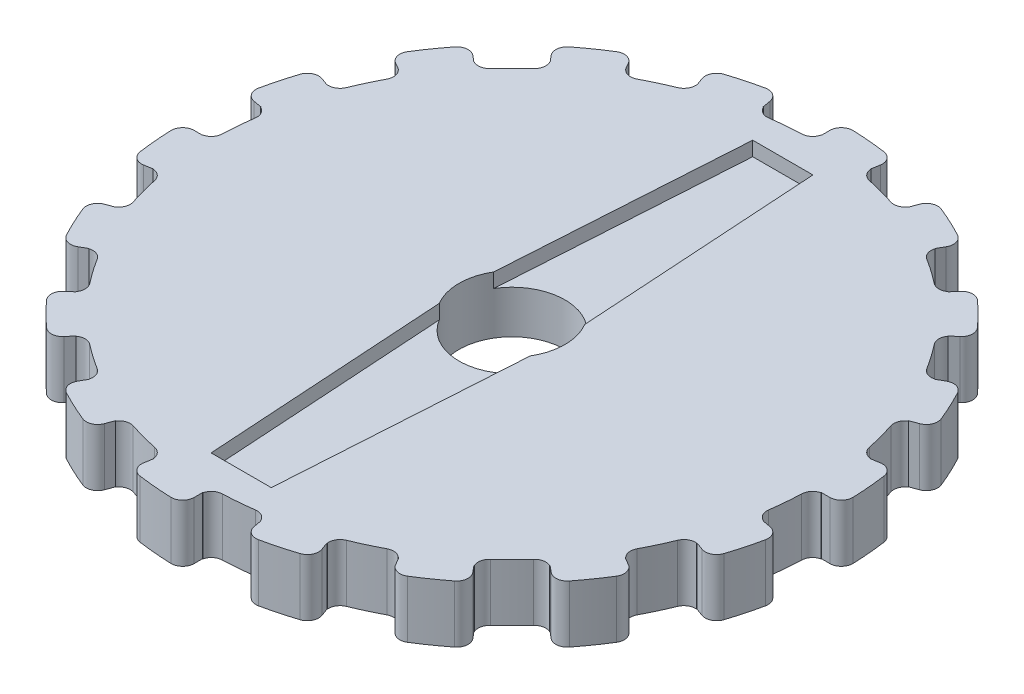
from build123d import *

# Parameters (mm, degrees)
CROQUIS1_R              = 3.7
SALIENTE_EXTRUIR1_DEPTH = 4
CORTAR_EXTRUIR1_START   = -1
CORTAR_EXTRUIR1_DEPTH   = 1
CORTAR_EXTRUIR2_START   = -4
CORTAR_EXTRUIR2_DEPTH   = 4
MATRIZC1_COUNT          = 18
ESCALA1_SCALE           = 0.99


with BuildPart() as part:
    # Croquis1 → Saliente-Extruir1 (new body)
    with BuildSketch(Plane(origin=(0, 0, 0), x_dir=(1, 0, 0), z_dir=(0, 1, 0))):
        with BuildLine():
            Line((3.750800638, 21.271847465), (4.167556264, 23.635386072))
            ThreePointArc((4.167556264, 23.635386072), (2.091737826, 23.908672754), (0, 24))
            Line((0, 24), (0, 21.6))
            ThreePointArc((0, 21.6), (-1.882564043, 21.517805479), (-3.750800638, 21.271847465))
            Line((-3.750800638, 21.271847465), (-4.167556264, 23.635386072))
            ThreePointArc((-4.167556264, 23.635386072), (-6.211657082, 23.182219831), (-8.20848344, 22.552622899))
            Line((-8.20848344, 22.552622899), (-7.387635096, 20.297360609))
            ThreePointArc((-7.387635096, 20.297360609), (-9.128554454, 19.5762482), (-10.8, 18.706148722))
            Line((-10.8, 18.706148722), (-12, 20.784609691))
            ThreePointArc((-12, 20.784609691), (-13.765834472, 19.659649063), (-15.426902632, 18.385066635))
            Line((-15.426902632, 18.385066635), (-13.884212369, 16.546559971))
            ThreePointArc((-13.884212369, 16.546559971), (-15.273506474, 15.273506474), (-16.546559971, 13.884212369))
            Line((-16.546559971, 13.884212369), (-18.385066635, 15.426902632))
            ThreePointArc((-18.385066635, 15.426902632), (-19.659649063, 13.765834472), (-20.784609691, 12))
            Line((-20.784609691, 12), (-18.706148722, 10.8))
            ThreePointArc((-18.706148722, 10.8), (-19.5762482, 9.128554454), (-20.297360609, 7.387635096))
            Line((-20.297360609, 7.387635096), (-22.552622899, 8.20848344))
            ThreePointArc((-22.552622899, 8.20848344), (-23.182219831, 6.211657082), (-23.635386072, 4.167556264))
            Line((-23.635386072, 4.167556264), (-21.271847465, 3.750800638))
            ThreePointArc((-21.271847465, 3.750800638), (-21.517805479, 1.882564043), (-21.6, 0))
            Line((-21.6, 0), (-24, 0))
            ThreePointArc((-24, 0), (-23.908672754, -2.091737826), (-23.635386072, -4.167556264))
            Line((-23.635386072, -4.167556264), (-21.271847465, -3.750800638))
            ThreePointArc((-21.271847465, -3.750800638), (-20.863997848, -5.590491374), (-20.297360609, -7.387635096))
            Line((-20.297360609, -7.387635096), (-22.552622899, -8.20848344))
            ThreePointArc((-22.552622899, -8.20848344), (-21.751386889, -10.142838282), (-20.784609691, -12))
            Line((-20.784609691, -12), (-18.706148722, -10.8))
            ThreePointArc((-18.706148722, -10.8), (-17.693684157, -12.389251025), (-16.546559971, -13.884212369))
            Line((-16.546559971, -13.884212369), (-18.385066635, -15.426902632))
            ThreePointArc((-18.385066635, -15.426902632), (-16.970562748, -16.970562748), (-15.426902632, -18.385066635))
            Line((-15.426902632, -18.385066635), (-13.884212369, -16.546559971))
            ThreePointArc((-13.884212369, -16.546559971), (-12.389251025, -17.693684157), (-10.8, -18.706148722))
            Line((-10.8, -18.706148722), (-12, -20.784609691))
            ThreePointArc((-12, -20.784609691), (-10.142838282, -21.751386889), (-8.20848344, -22.552622899))
            Line((-8.20848344, -22.552622899), (-7.387635096, -20.297360609))
            ThreePointArc((-7.387635096, -20.297360609), (-5.590491374, -20.863997848), (-3.750800638, -21.271847465))
            Line((-3.750800638, -21.271847465), (-4.167556264, -23.635386072))
            ThreePointArc((-4.167556264, -23.635386072), (-2.091737826, -23.908672754), (0, -24))
            Line((0, -24), (0, -21.6))
            ThreePointArc((0, -21.6), (1.882564043, -21.517805479), (3.750800638, -21.271847465))
            Line((3.750800638, -21.271847465), (4.167556264, -23.635386072))
            ThreePointArc((4.167556264, -23.635386072), (6.211657082, -23.182219831), (8.20848344, -22.552622899))
            Line((8.20848344, -22.552622899), (7.387635096, -20.297360609))
            ThreePointArc((7.387635096, -20.297360609), (9.128554454, -19.5762482), (10.8, -18.706148722))
            Line((10.8, -18.706148722), (12, -20.784609691))
            ThreePointArc((12, -20.784609691), (13.765834472, -19.659649063), (15.426902632, -18.385066635))
            Line((15.426902632, -18.385066635), (13.884212369, -16.546559971))
            ThreePointArc((13.884212369, -16.546559971), (15.273506474, -15.273506474), (16.546559971, -13.884212369))
            Line((16.546559971, -13.884212369), (18.385066635, -15.426902632))
            ThreePointArc((18.385066635, -15.426902632), (19.659649063, -13.765834472), (20.784609691, -12))
            Line((20.784609691, -12), (18.706148722, -10.8))
            ThreePointArc((18.706148722, -10.8), (19.5762482, -9.128554454), (20.297360609, -7.387635096))
            Line((20.297360609, -7.387635096), (22.552622899, -8.20848344))
            ThreePointArc((22.552622899, -8.20848344), (23.182219831, -6.211657082), (23.635386072, -4.167556264))
            Line((23.635386072, -4.167556264), (21.271847465, -3.750800638))
            ThreePointArc((21.271847465, -3.750800638), (21.517805479, -1.882564043), (21.6, 0))
            Line((21.6, 0), (24, 0))
            ThreePointArc((24, 0), (23.908672754, 2.091737826), (23.635386072, 4.167556264))
            Line((23.635386072, 4.167556264), (21.271847465, 3.750800638))
            ThreePointArc((21.271847465, 3.750800638), (20.863997848, 5.590491374), (20.297360609, 7.387635096))
            Line((20.297360609, 7.387635096), (22.552622899, 8.20848344))
            ThreePointArc((22.552622899, 8.20848344), (21.751386889, 10.142838282), (20.784609691, 12))
            Line((20.784609691, 12), (18.706148722, 10.8))
            ThreePointArc((18.706148722, 10.8), (17.693684157, 12.389251025), (16.546559971, 13.884212369))
            Line((16.546559971, 13.884212369), (18.385066635, 15.426902632))
            ThreePointArc((18.385066635, 15.426902632), (16.970562748, 16.970562748), (15.426902632, 18.385066635))
            Line((15.426902632, 18.385066635), (13.884212369, 16.546559971))
            ThreePointArc((13.884212369, 16.546559971), (12.389251025, 17.693684157), (10.8, 18.706148722))
            Line((10.8, 18.706148722), (12, 20.784609691))
            ThreePointArc((12, 20.784609691), (10.142838282, 21.751386889), (8.20848344, 22.552622899))
            Line((8.20848344, 22.552622899), (7.387635096, 20.297360609))
            ThreePointArc((7.387635096, 20.297360609), (5.590491374, 20.863997848), (3.750800638, 21.271847465))
        make_face()
        Circle(CROQUIS1_R, mode=Mode.SUBTRACT)
    extrude(amount=SALIENTE_EXTRUIR1_DEPTH)

    # Croquis2 → Cortar-Extruir1 (cut)
    with BuildSketch(Plane(origin=(0, 4, 0), x_dir=(1, 0, 0), z_dir=(0, 1, 0)).offset(CORTAR_EXTRUIR1_START)):
        with BuildLine():
            Line((-2.1, 18.9), (2.1, 18.9))
            Line((2.1, 18.9), (3.174901573, 1.9))
            ThreePointArc((3.174901573, 1.9), (0, 3.7), (-3.174901573, 1.9))
            Line((-3.174901573, 1.9), (-2.1, 18.9))
        make_face()
        with BuildLine():
            Line((3.174901573, -1.9), (2.1, -18.9))
            Line((2.1, -18.9), (-2.1, -18.9))
            Line((-2.1, -18.9), (-3.174901573, -1.9))
            ThreePointArc((-3.174901573, -1.9), (0, -3.7), (3.174901573, -1.9))
        make_face()
    extrude(amount=CORTAR_EXTRUIR1_DEPTH, mode=Mode.SUBTRACT)

    # Croquis3 → Cortar-Extruir2 (cut)
    with BuildSketch(Plane(origin=(0, 4, 0), x_dir=(1, 0, 0), z_dir=(0, 1, 0)).offset(CORTAR_EXTRUIR2_START)):
        with BuildLine():
            ThreePointArc((3.175076951, 22.779791183), (3.711585598, 22.45804677), (3.852485694, 21.848532078))
            Line((3.852485694, 21.848532078), (4.167556264, 23.635386072))
            ThreePointArc((4.167556264, 23.635386072), (2.091737826, 23.908672754), (0, 24))
            Line((0, 24), (0, 22.185580903))
            ThreePointArc((0, 22.185580903), (0.244600623, 22.761368652), (0.828828829, 22.985061296))
            ThreePointArc((0.828828829, 22.985061296), (2.004582083, 22.912478056), (3.175076951, 22.779791183))
        make_face()
        with BuildLine():
            ThreePointArc((7.367181438, 20.304793465), (5.590491374, 20.863997848), (3.772230453, 21.268057678))
            ThreePointArc((3.772230453, 21.268057678), (3.963826364, 20.79432449), (4.403089895, 20.533212106))
            ThreePointArc((4.403089895, 20.533212106), (5.435199947, 20.284442352), (6.453418349, 19.983828252))
            ThreePointArc((6.453418349, 19.983828252), (6.964387918, 19.990326445), (7.367181438, 20.304793465))
        make_face()
    cortar_extruir2 = extrude(amount=CORTAR_EXTRUIR2_DEPTH, mode=Mode.SUBTRACT)

    # MatrizC1: Cortar-Extruir2 ×18 about axis
    matrizc1_axis = Axis((0, 4, 0), (0, -1, 0))
    for i in range(1, MATRIZC1_COUNT):
        add(cortar_extruir2.rotate(matrizc1_axis, i * 360 / MATRIZC1_COUNT), mode=Mode.SUBTRACT)


with BuildPart() as part_1:
    # Escala1: scaled about (0, 1.957486586, 0)
    add(part.part.scale(ESCALA1_SCALE).moved(Location((0, 0.019574866, 0))))


solid = part_1.part
